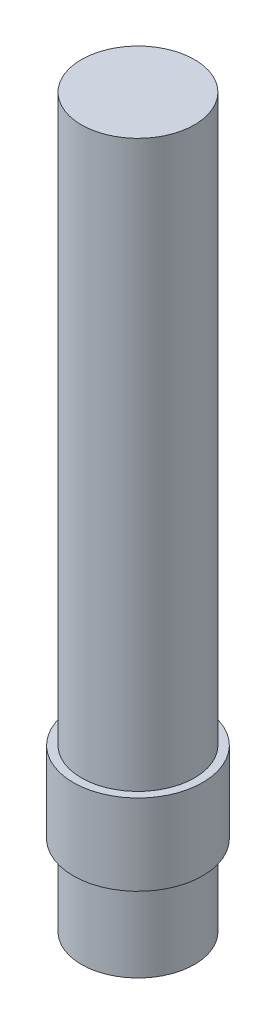
from build123d import *

# Parameters (mm, degrees)
SKETCH1_R           = 3.5
BOSS_EXTRUDE1_DEPTH = 5
SKETCH2_R           = 4
BOSS_EXTRUDE2_DEPTH = 5
SKETCH3_R           = 3.5
BOSS_EXTRUDE3_DEPTH = 35


with BuildPart() as part:
    # Sketch1 → Boss-Extrude1 (new body)
    with BuildSketch(Plane(origin=(0, 0, 0), x_dir=(1, 0, 0), z_dir=(0, 1, 0))):
        with Locations(Location((0, 0, 0), (0, 0, 270))):  # turned: the seam where the file's is
            Circle(SKETCH1_R)
    extrude(amount=BOSS_EXTRUDE1_DEPTH)

    # Sketch2 → Boss-Extrude2 (add)
    with BuildSketch(Plane(origin=(0, 5, 0), x_dir=(1, 0, 0), z_dir=(0, 1, 0))):
        with Locations(Location((0, 0, 0), (0, 0, 270))):  # turned: the seam where the file's is
            Circle(SKETCH2_R)
    extrude(amount=BOSS_EXTRUDE2_DEPTH)

    # Sketch3 → Boss-Extrude3 (add)
    with BuildSketch(Plane(origin=(0, 10, 0), x_dir=(1, 0, 0), z_dir=(0, 1, 0))):
        with Locations(Location((0, 0, 0), (0, 0, 270))):  # turned: the seam where the file's is
            Circle(SKETCH3_R)
    extrude(amount=BOSS_EXTRUDE3_DEPTH)


solid = part.part
